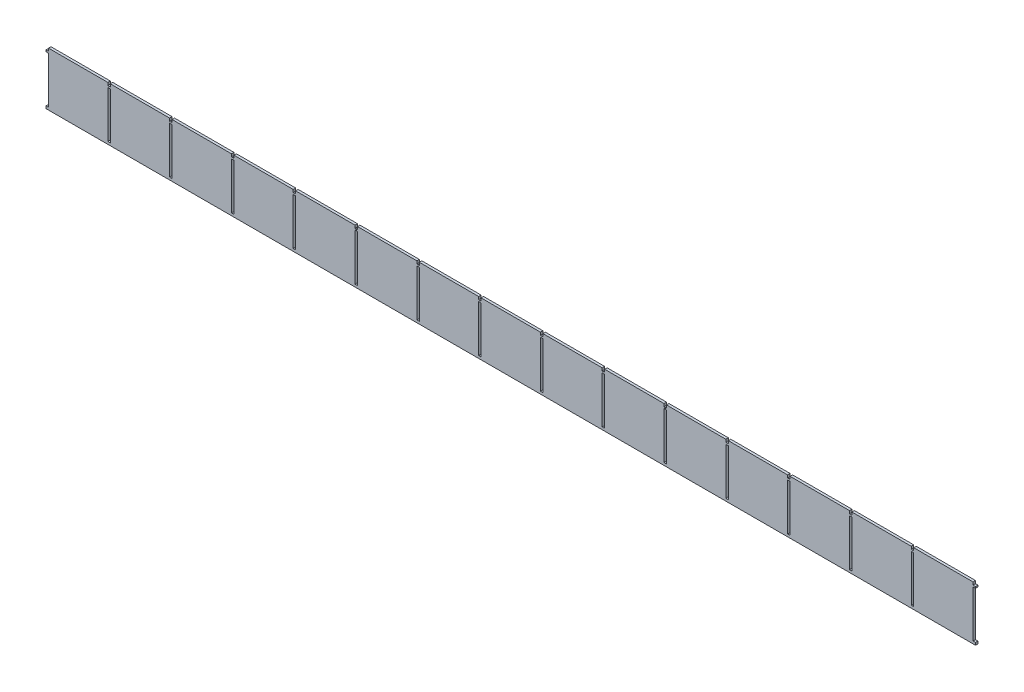
from build123d import *

# Parameters (mm, degrees)
BOSS_EXTRUDE1_DEPTH = 4


with BuildPart() as part:
    # Sketch2 → Boss-Extrude1 (new body)
    with BuildSketch(Plane.XY):
        Polygon((-752, 38.99099655), (-752, 36.297950089), (-748, 36.297950089), (-748, -39.401624923), (-752, -39.401624923), (-752, -43.401624923), (752, -43.401624923), (752, -39.401624923), (748, -39.401624923), (748, 36.297950089), (752, 36.297950089), (752, 38.99099655), (748, 38.99099655), (748, 43.401624923), (652, 43.401624923), (652, 38.99099655), (650.1, 38.99099655), (650.1, 36.297950089), (652, 36.297950089), (652, -39.401624923), (648, -39.401624923), (648, 36.297950089), (649.9, 36.297950089), (649.9, 38.99099655), (648, 38.99099655), (648, 43.401624923), (552, 43.401624923), (552, 38.99099655), (550.1, 38.99099655), (550.1, 36.297950089), (552, 36.297950089), (552, -39.401624923), (548, -39.401624923), (548, 36.297950089), (549.9, 36.297950089), (549.9, 38.99099655), (548, 38.99099655), (548, 43.401624923), (452, 43.401624923), (452, 38.99099655), (450.1, 38.99099655), (450.1, 36.297950089), (452, 36.297950089), (452, -39.401624923), (448, -39.401624923), (448, 36.297950089), (449.9, 36.297950089), (449.9, 38.99099655), (448, 38.99099655), (448, 43.401624923), (352, 43.401624923), (352, 38.99099655), (350.1, 38.99099655), (350.1, 36.297950089), (352, 36.297950089), (352, -39.401624923), (350, -39.401624923), (348, -39.401624923), (348, 36.297950089), (349.9, 36.297950089), (349.9, 38.99099655), (348, 38.99099655), (348, 43.401624923), (252, 43.401624923), (252, 38.99099655), (250.1, 38.99099655), (250.1, 36.297950089), (252, 36.297950089), (252, -39.401624923), (250, -39.401624923), (248, -39.401624923), (248, 36.297950089), (249.9, 36.297950089), (249.9, 38.99099655), (248, 38.99099655), (248, 43.401624923), (152, 43.401624923), (152, 38.99099655), (150.1, 38.99099655), (150.1, 36.297950089), (152, 36.297950089), (152, -39.401624923), (148, -39.401624923), (148, 36.297950089), (149.9, 36.297950089), (149.9, 38.99099655), (148, 38.99099655), (148, 43.401624923), (52, 43.401624923), (52, 38.99099655), (50.1, 38.99099655), (50.1, 36.297950089), (52, 36.297950089), (52, -39.401624923), (48, -39.401624923), (48, 36.297950089), (49.9, 36.297950089), (49.9, 38.99099655), (48, 38.99099655), (48, 43.401624923), (-48, 43.401624923), (-48, 38.99099655), (-49.9, 38.99099655), (-49.9, 36.297950089), (-48, 36.297950089), (-48, -39.401624923), (-52, -39.401624923), (-52, 36.297950089), (-50.1, 36.297950089), (-50.1, 38.99099655), (-52, 38.99099655), (-52, 43.401624923), (-148, 43.401624923), (-148, 38.99099655), (-149.9, 38.99099655), (-149.9, 36.297950089), (-148, 36.297950089), (-148, -39.401624923), (-152, -39.401624923), (-152, 36.297950089), (-150.1, 36.297950089), (-150.1, 38.99099655), (-152, 38.99099655), (-152, 43.401624923), (-248, 43.401624923), (-248, 38.99099655), (-249.9, 38.99099655), (-249.9, 36.297950089), (-248, 36.297950089), (-248, -39.401624923), (-252, -39.401624923), (-252, 36.297950089), (-250.1, 36.297950089), (-250.1, 38.99099655), (-252, 38.99099655), (-252, 43.401624923), (-348, 43.401624923), (-348, 38.99099655), (-349.9, 38.99099655), (-349.9, 36.297950089), (-348, 36.297950089), (-348, -39.401624923), (-352, -39.401624923), (-352, 36.297950089), (-350.1, 36.297950089), (-350.1, 38.99099655), (-352, 38.99099655), (-352, 43.401624923), (-448, 43.401624923), (-448, 38.99099655), (-449.9, 38.99099655), (-449.9, 36.297950089), (-448, 36.297950089), (-448, -39.401624923), (-452, -39.401624923), (-452, 36.297950089), (-450.1, 36.297950089), (-450.1, 38.99099655), (-452, 38.99099655), (-452, 43.401624923), (-548, 43.401624923), (-548, 38.99099655), (-549.9, 38.99099655), (-549.9, 36.297950089), (-548, 36.297950089), (-548, -39.401624923), (-552, -39.401624923), (-552, 36.297950089), (-550.1, 36.297950089), (-550.1, 38.99099655), (-552, 38.99099655), (-552, 43.401624923), (-648, 43.401624923), (-648, 38.99099655), (-649.9, 38.99099655), (-649.9, 36.297950089), (-648, 36.297950089), (-648, -39.401624923), (-652, -39.401624923), (-652, 36.297950089), (-650.1, 36.297950089), (-650.1, 38.99099655), (-652, 38.99099655), (-652, 43.401624923), (-748, 43.401624923), (-748, 38.99099655), align=None)
    extrude(amount=BOSS_EXTRUDE1_DEPTH)


solid = part.part
